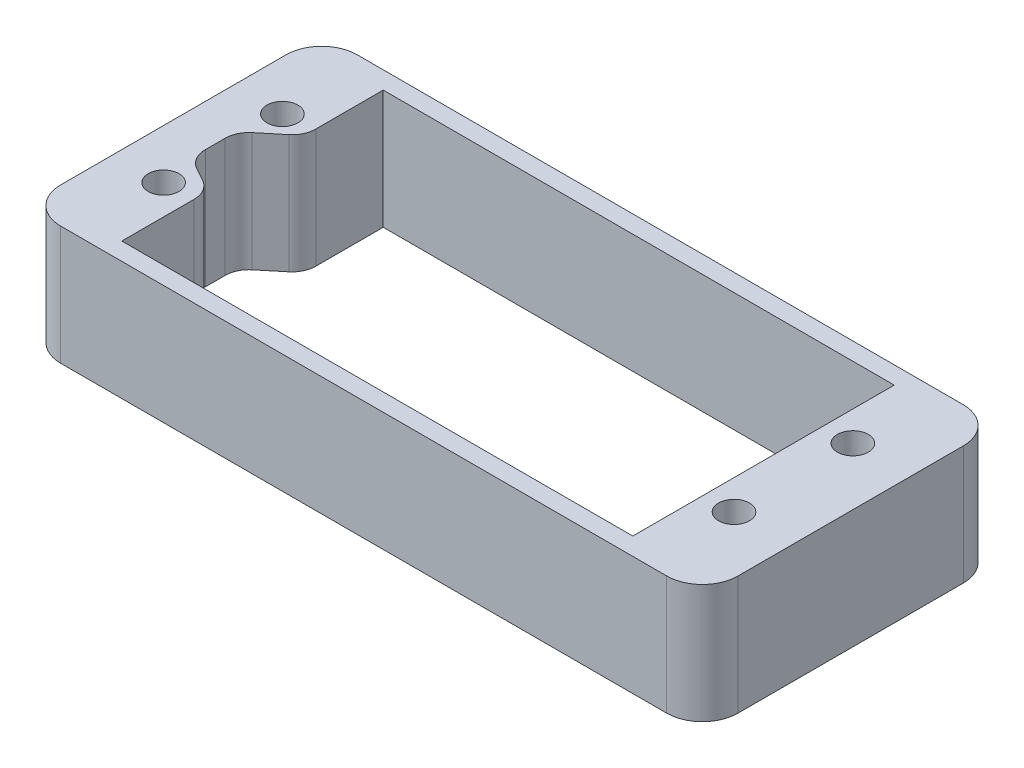
from build123d import *

# Parameters (mm, degrees)
CROQUIS1_W              = 57
CROQUIS1_H              = 24.959470006
CROQUIS1_W_2            = 43
CROQUIS1_H_2            = 22
MAIN_DEPTH              = 28
CROQUIS2_W              = 27.955905163
CROQUIS2_H              = 20.987971864
CORTE_CAJA_DEPTH        = 24.95947
CROQUIS3_W              = 32
CROQUIS3_H              = 24.959470006
SALIENTE_EXTRUIR2_DEPTH = 2.25
REDONDEO_LATERALES_R    = 3
CROQUIS7_R              = 1.3
TALADROS_BASE_DEPTH     = 11
CAJEADO_CABLE_DEPTH     = 10
CAJEADO_REDONDEO_R      = 2
CORTAR_EXTRUIR1_DEPTH   = 24.95947


with BuildPart() as part:
    # Croquis1 → Main (new body)
    with BuildSketch(Plane(origin=(0, 0, 0), x_dir=(1, 0, 0), z_dir=(0, 1, 0))):
        with Locations((11.181999645, 13.428246359)):
            Rectangle(CROQUIS1_W, CROQUIS1_H)
        with Locations((10.844499645, 13.430306654)):
            Rectangle(CROQUIS1_W_2, CROQUIS1_H_2, mode=Mode.SUBTRACT)
    extrude(amount=MAIN_DEPTH)

    # Croquis2 → Corte Caja (cut)
    with BuildSketch(Plane.XY.offset(-0.948511356)):
        with Locations((28.659952227, 20.493985932)):
            Rectangle(CROQUIS2_W, CROQUIS2_H)
    extrude(amount=-CORTE_CAJA_DEPTH, mode=Mode.SUBTRACT)

    # Croquis3 → Saliente-Extruir2 (add)
    with BuildSketch(Plane(origin=(0, 28, 0), x_dir=(1, 0, 0), z_dir=(0, 1, 0))):
        with Locations((-1.318000355, 13.428246359)):
            Rectangle(CROQUIS3_W, CROQUIS3_H)
    extrude(amount=SALIENTE_EXTRUIR2_DEPTH)

    # Redondeo Laterales
    redondeo_laterales_edges = [part.edges().sort_by_distance(p)[0] for p in [
        (39.681999645, 5, -25.907981362),
        (39.681999645, 5, -0.948511356),
        (-17.318000355, 15.125, -25.907981362),
        (-17.318000355, 15.125, -0.948511356),
    ]]
    fillet(redondeo_laterales_edges, radius=REDONDEO_LATERALES_R)

    # Croquis7 → Taladros Base (cut)
    with BuildSketch(Plane.XZ):
        with Locations((-13.155500355, -8.448511356)):
            Circle(CROQUIS7_R)
        with Locations((-13.155500355, -18.448511356)):
            Circle(CROQUIS7_R)
        with Locations((34.844499645, -8.448511356)):
            Circle(CROQUIS7_R)
        with Locations((34.844499645, -18.448511356)):
            Circle(CROQUIS7_R)
    extrude(amount=-TALADROS_BASE_DEPTH, mode=Mode.SUBTRACT)

    # Croquis8 → Cajeado cable (cut)
    with BuildSketch(Plane.XZ):
        Polygon((-10.655500355, -17.809410949), (-10.655500355, -9.693483102), (-13.79985022, -11.41721999), (-13.79985022, -15.216689513), align=None)
    extrude(amount=-CAJEADO_CABLE_DEPTH, mode=Mode.SUBTRACT)

    # Cajeado Redondeo
    cajeado_redondeo_edges = [part.edges().sort_by_distance(p)[0] for p in [
        (-13.79985022, 5, -11.41721999),
        (-10.655500355, 5, -9.693483102),
        (-10.655500355, 5, -17.809410949),
        (-13.79985022, 5, -15.216689513),
    ]]
    fillet(cajeado_redondeo_edges, radius=CAJEADO_REDONDEO_R)

    # Croquis10 → Cortar-Extruir1 (cut)
    with BuildSketch(Plane.XY.offset(-0.948511356)):
        Polygon((-18.751407395, 10), (41.252258099, 10), (41.252258099, 38.904482254), (-18.751407395, 38.904482254), (-18.751407395, 38.898632989), align=None)
    extrude(amount=-CORTAR_EXTRUIR1_DEPTH, mode=Mode.SUBTRACT)


solid = part.part
